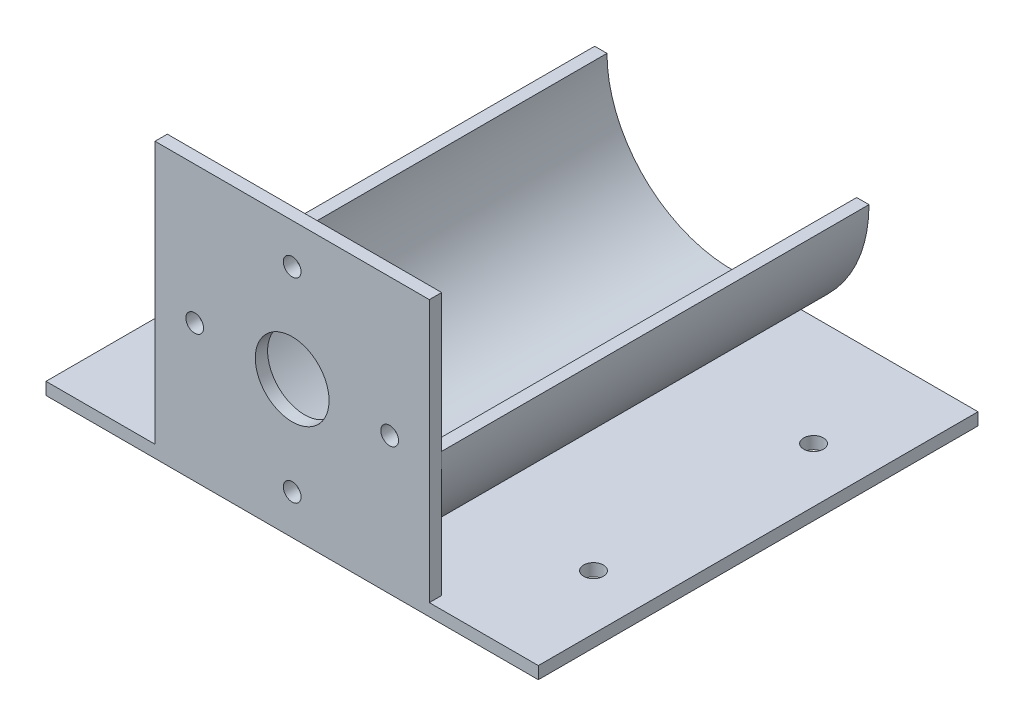
from build123d import *

# Parameters (mm, degrees)
SKETCH1_W           = 127
SKETCH1_H           = 3.175
BOSS_EXTRUDE2_DEPTH = 110.236
SKETCH2_R           = 2.286
SKETCH2_R_2         = 9.5123
BOSS_EXTRUDE3_DEPTH = 3.175
SKETCH3_R           = 2.54
CUT_EXTRUDE1_DEPTH  = 4.175


with BuildPart() as part:
    # Sketch1 → Boss-Extrude2 (new body)
    with BuildSketch(Plane.XY):
        with BuildLine():
            Line((-35.3822, 0), (-32.2072, 0))
            ThreePointArc((-32.2072, 0), (0, -32.2072), (32.2072, 0))
            Line((32.2072, 0), (35.3822, 0))
            ThreePointArc((35.3822, 0), (0, -35.3822), (-35.3822, 0))
        make_face()
        with Locations((0, -33.7947)):
            Rectangle(SKETCH1_W, SKETCH1_H)
    extrude(amount=BOSS_EXTRUDE2_DEPTH)

    # Sketch2 → Boss-Extrude3 (add)
    with BuildSketch(Plane.XY.offset(110.236)):
        Polygon((-35.3822, -35.3822), (35.3822, -35.3822), (63.5, -35.3822), (63.5, -32.2072), (35.3822, -32.2072), (35.3822, 35.4838), (-35.3822, 35.4838), (-35.3822, -32.2072), (-63.5, -32.2072), (-63.5, -35.3822), align=None)
        with Locations((-25.146, 0)):
            Circle(SKETCH2_R, mode=Mode.SUBTRACT)
        with Locations((0, 25.146)):
            Circle(SKETCH2_R, mode=Mode.SUBTRACT)
        with Locations((25.146, 0)):
            Circle(SKETCH2_R, mode=Mode.SUBTRACT)
        with Locations((0, -25.146)):
            Circle(SKETCH2_R, mode=Mode.SUBTRACT)
        Circle(SKETCH2_R_2, mode=Mode.SUBTRACT)
    extrude(amount=BOSS_EXTRUDE3_DEPTH)

    # Sketch3 → Cut-Extrude1 (cut, through all)
    with BuildSketch(Plane(origin=(0, -32.2072, 0), x_dir=(1, 0, 0), z_dir=(0, 1, 0))):
        with Locations((49.403, -85.09)):
            Circle(SKETCH3_R)
        with Locations((49.403, -28.321)):
            Circle(SKETCH3_R)
        with Locations((-49.403, -85.09)):
            Circle(SKETCH3_R)
        with Locations((-49.403, -28.321)):
            Circle(SKETCH3_R)
    extrude(amount=-CUT_EXTRUDE1_DEPTH, mode=Mode.SUBTRACT)


solid = part.part
